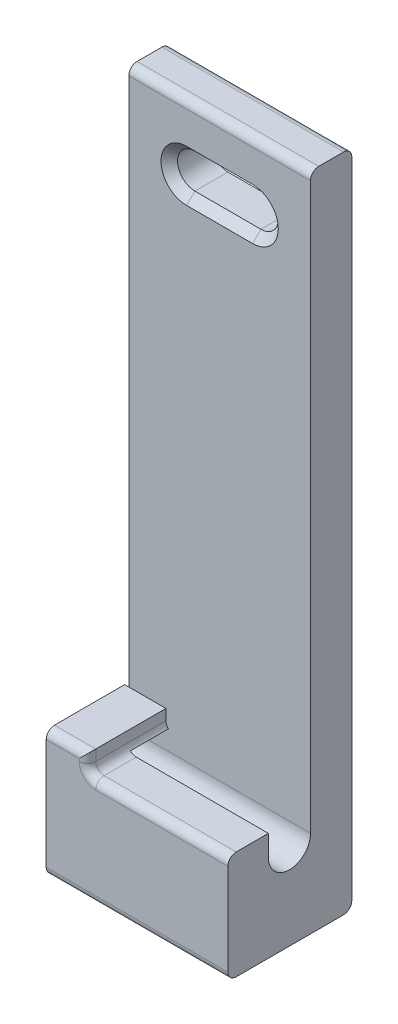
from build123d import *

# Parameters (mm, degrees)
SKETCH1_W           = 15
SKETCH1_H           = 80
BOSS_EXTRUDE1_DEPTH = 22
CUT_EXTRUDE1_DEPTH  = 23
CUT_EXTRUDE2_DEPTH  = 6
CHAMFER1_SIZE       = 1
SKETCH6_W           = 4.9
SKETCH6_H           = 0.3
BOSS_EXTRUDE2_DEPTH = 5
FILLET2_R           = 1


with BuildPart() as part:
    # Sketch1 → Boss-Extrude1 (new body)
    with BuildSketch(Plane(origin=(0, 0, 0), x_dir=(0, 0, -1), z_dir=(1, 0, 0))):
        with Locations((-7.5, 40)):
            Rectangle(SKETCH1_W, SKETCH1_H)
    extrude(amount=BOSS_EXTRUDE1_DEPTH)

    # Sketch2 → Cut-Extrude1 (cut, through all)
    with BuildSketch(Plane(origin=(22, 0, 0), x_dir=(0, 0, -1), z_dir=(1, 0, 0))):
        with BuildLine():
            Line((-15, 80), (-15, 13.1))
            Line((-15, 13.1), (-10.1, 13.1))
            Line((-10.1, 13.1), (-10.1, 10.55))
            ThreePointArc((-10.1, 10.55), (-7.55, 8), (-5, 10.55))
            Line((-5, 10.55), (-5, 80))
            Line((-5, 80), (-15, 80))
        make_face()
    extrude(amount=-CUT_EXTRUDE1_DEPTH, mode=Mode.SUBTRACT)

    # Sketch3 → Cut-Extrude2 (cut, through all)
    with BuildSketch(Plane.XY.offset(5)):
        with BuildLine():
            Line((7, 74.1), (15, 74.1))
            ThreePointArc((15, 74.1), (17.1, 72), (15, 69.9))
            Line((15, 69.9), (7, 69.9))
            ThreePointArc((7, 69.9), (4.9, 72), (7, 74.1))
        make_face()
    extrude(amount=-CUT_EXTRUDE2_DEPTH, mode=Mode.SUBTRACT)

    # Chamfer1
    chamfer1_edges = [part.edges().sort_by_distance(p)[0] for p in [
        (4.9, 72, 5),
        (11, 69.9, 5),
        (17.1, 72, 5),
        (11, 74.1, 5),
    ]]
    chamfer(chamfer1_edges, length=CHAMFER1_SIZE)

    # Sketch6 → Boss-Extrude2 (add)
    with BuildSketch(Plane.ZY):
        Polygon((10.1, 13.4), (15, 13.4), (15, 15.4), (5.5, 15.4), (5.5, 13.4), align=None)
        with Locations((12.55, 13.25)):
            Rectangle(SKETCH6_W, SKETCH6_H)
    extrude(amount=-BOSS_EXTRUDE2_DEPTH)

    # Fillet2
    fillet2_edges = [part.edges().sort_by_distance(p)[0] for p in [
        (5, 14.25, 15),
        (11, 0, 0),
        (11, 80, 0),
        (11, 80, 5),
        (13.5, 13.1, 15),
        (11, 0, 15),
        (2.5, 15.4, 15),
        (5, 13.1, 12.55),
    ]]
    fillet(fillet2_edges, radius=FILLET2_R)


solid = part.part
